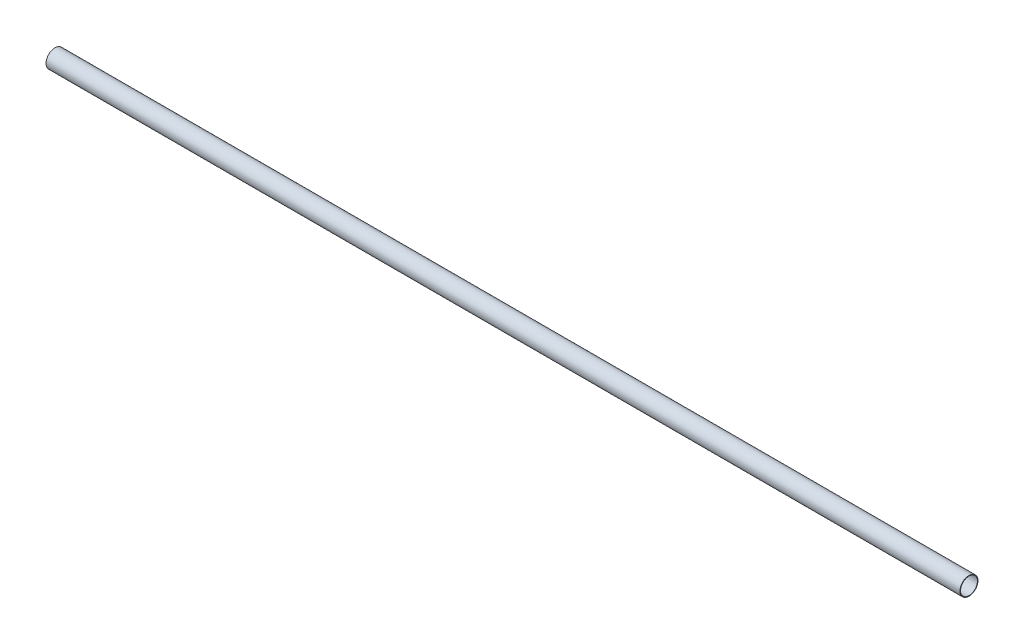
from build123d import *

# Parameters (mm, degrees)
SKETCH1_R      = 14.2875
SKETCH1_R_2    = 13.3985
EXTRUDE1_DEPTH = 723.9


with BuildPart() as part:
    # Sketch1 → Extrude1 (new body, symmetric)
    with BuildSketch(Plane(origin=(0, 0, 0), x_dir=(0, 0, -1), z_dir=(1, 0, 0))):
        Circle(SKETCH1_R)
        Circle(SKETCH1_R_2, mode=Mode.SUBTRACT)
    extrude(amount=EXTRUDE1_DEPTH, both=True)


solid = part.part
